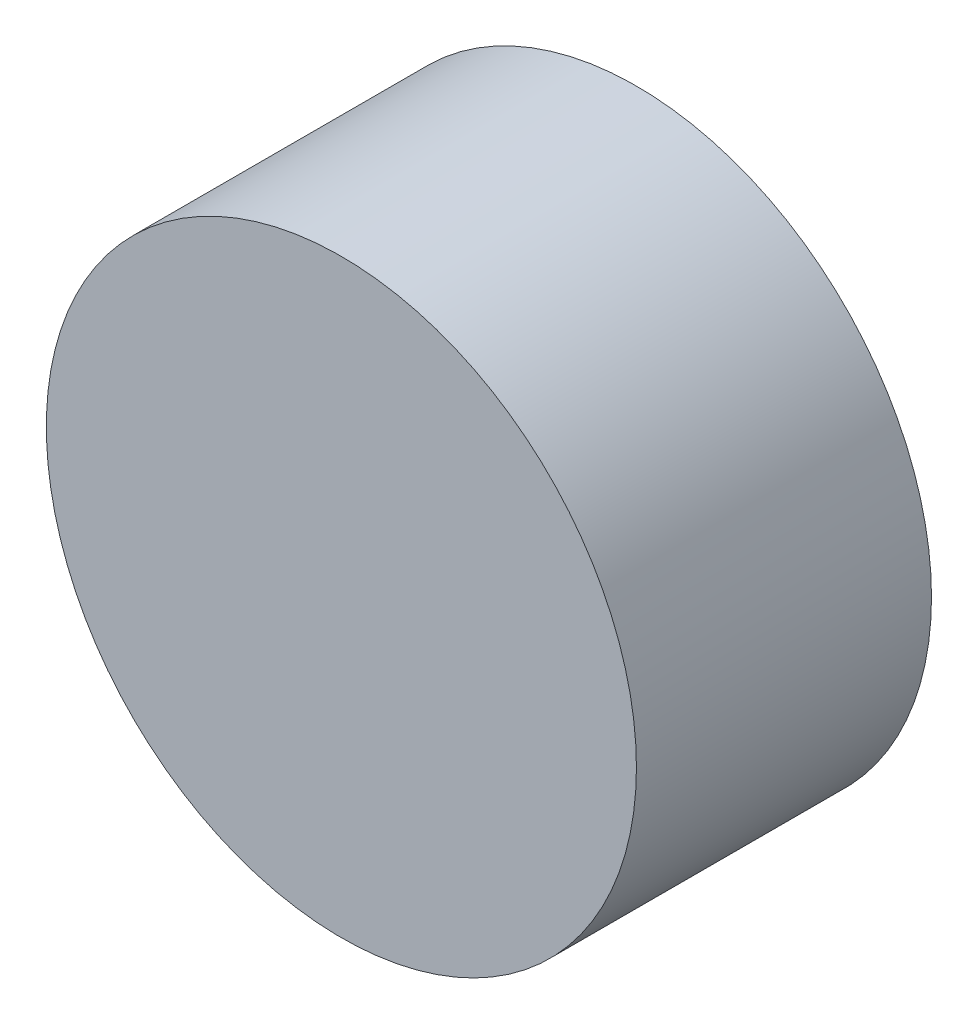
from build123d import *

# Parameters (mm, degrees)
SKETCH1_R           = 50.8
BOSS_EXTRUDE1_DEPTH = 50.8


with BuildPart() as part:
    # Sketch1 → Boss-Extrude1 (new body)
    with BuildSketch(Plane.XY):
        Circle(SKETCH1_R)
    extrude(amount=BOSS_EXTRUDE1_DEPTH)


solid = part.part
